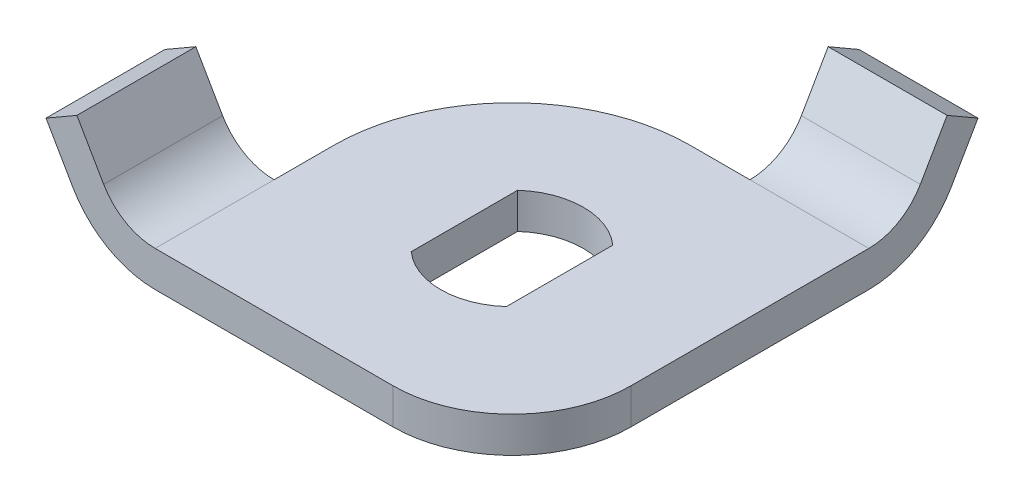
from build123d import *

# Parameters (mm, degrees)
SKETCH1_W           = 30
SKETCH1_H           = 30
BOSS_EXTRUDE1_DEPTH = 3
BOSS_EXTRUDE2_DEPTH = 10
FILLET1_R           = 15
FILLET2_R           = 10
BOSS_EXTRUDE3_DEPTH = 10
CUT_EXTRUDE1_DEPTH  = 3


with BuildPart() as part:
    # Sketch1 → Boss-Extrude1 (new body)
    with BuildSketch(Plane(origin=(0, 0, 0), x_dir=(1, 0, 0), z_dir=(0, 1, 0))):
        Rectangle(SKETCH1_W, SKETCH1_H)
    extrude(amount=BOSS_EXTRUDE1_DEPTH)

    # Sketch2 → Boss-Extrude2 (add)
    with BuildSketch(Plane.XY.offset(15)):
        with BuildLine():
            Line((-21.580127019, 9.397114317), (-24.17820323, 7.897114317))
            Line((-24.17820323, 7.897114317), (-21.92820323, 4))
            ThreePointArc((-21.92820323, 4), (-19, 1.07179677), (-15, 0))
            Line((-15, 0), (-15, 3))
            ThreePointArc((-15, 3), (-17.5, 3.669872981), (-19.330127019, 5.5))
            Line((-19.330127019, 5.5), (-21.580127019, 9.397114317))
        make_face()
    extrude(amount=-BOSS_EXTRUDE2_DEPTH)

    # Fillet1
    fillet1_edges = [part.edges().sort_by_distance(p)[0] for p in [
        (-15, 1.5, -15),
    ]]
    fillet(fillet1_edges, radius=FILLET1_R)

    # Fillet2
    fillet2_edges = [part.edges().sort_by_distance(p)[0] for p in [
        (15, 1.5, 15),
    ]]
    fillet(fillet2_edges, radius=FILLET2_R)

    # Sketch3 → Boss-Extrude3 (add)
    with BuildSketch(Plane(origin=(15, 0, 0), x_dir=(0, 0, -1), z_dir=(1, 0, 0))):
        with BuildLine():
            Line((15, 3), (15, 0))
            ThreePointArc((15, 0), (19, 1.07179677), (21.92820323, 4))
            Line((21.92820323, 4), (24.17820323, 7.897114317))
            Line((24.17820323, 7.897114317), (21.580127019, 9.397114317))
            Line((21.580127019, 9.397114317), (19.330127019, 5.5))
            ThreePointArc((19.330127019, 5.5), (17.5, 3.669872981), (15, 3))
        make_face()
    extrude(amount=-BOSS_EXTRUDE3_DEPTH)

    # Sketch4 → Cut-Extrude1 (cut)
    with BuildSketch(Plane.XZ):
        with BuildLine():
            Line((-4, -4.472135955), (-4, 4.472135955))
            ThreePointArc((-4, 4.472135955), (0, 6), (4, 4.472135955))
            Line((4, 4.472135955), (4, -4.472135955))
            ThreePointArc((4, -4.472135955), (0, -6), (-4, -4.472135955))
        make_face()
    extrude(amount=-CUT_EXTRUDE1_DEPTH, mode=Mode.SUBTRACT)


solid = part.part
